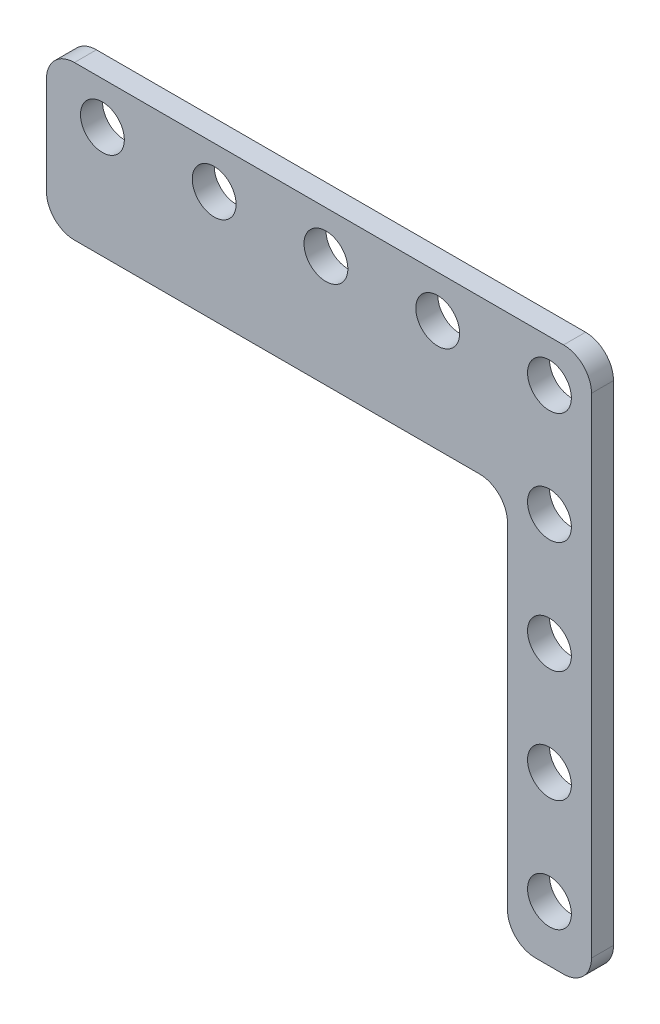
from build123d import *

# Parameters (mm, degrees)
SKETCH1_R           = 2.4892
BOSS_EXTRUDE1_DEPTH = 2.5


with BuildPart() as part:
    # Sketch1 → Boss-Extrude1 (new body)
    with BuildSketch(Plane.XY):
        with BuildLine():
            Line((-1.6002, -57.15), (1.6002, -57.15))
            ThreePointArc((1.6002, -57.15), (3.84526403, -56.22006403), (4.7752, -53.975))
            Line((4.7752, -53.975), (4.7752, 1.6002))
            ThreePointArc((4.7752, 1.6002), (3.84526403, 3.84526403), (1.6002, 4.7752))
            Line((1.6002, 4.7752), (-53.975, 4.7752))
            ThreePointArc((-53.975, 4.7752), (-56.22006403, 3.84526403), (-57.15, 1.6002))
            Line((-57.15, 1.6002), (-57.15, -9.525))
            ThreePointArc((-57.15, -9.525), (-56.22006403, -11.77006403), (-53.975, -12.7))
            Line((-53.975, -12.7), (-7.9502, -12.7))
            ThreePointArc((-7.9502, -12.7), (-5.70513597, -13.62993597), (-4.7752, -15.875))
            Line((-4.7752, -15.875), (-4.7752, -53.975))
            ThreePointArc((-4.7752, -53.975), (-3.84526403, -56.22006403), (-1.6002, -57.15))
        make_face()
        with Locations((-12.7, 0)):
            Circle(SKETCH1_R, mode=Mode.SUBTRACT)
        Circle(SKETCH1_R, mode=Mode.SUBTRACT)
        with Locations((-25.4, 0)):
            Circle(SKETCH1_R, mode=Mode.SUBTRACT)
        with Locations((-38.1, 0)):
            Circle(SKETCH1_R, mode=Mode.SUBTRACT)
        with Locations((-50.8, 0)):
            Circle(SKETCH1_R, mode=Mode.SUBTRACT)
        with Locations((0, -12.7)):
            Circle(SKETCH1_R, mode=Mode.SUBTRACT)
        with Locations((0, -25.4)):
            Circle(SKETCH1_R, mode=Mode.SUBTRACT)
        with Locations((0, -38.1)):
            Circle(SKETCH1_R, mode=Mode.SUBTRACT)
        with Locations((0, -50.8)):
            Circle(SKETCH1_R, mode=Mode.SUBTRACT)
    extrude(amount=-BOSS_EXTRUDE1_DEPTH)


solid = part.part
